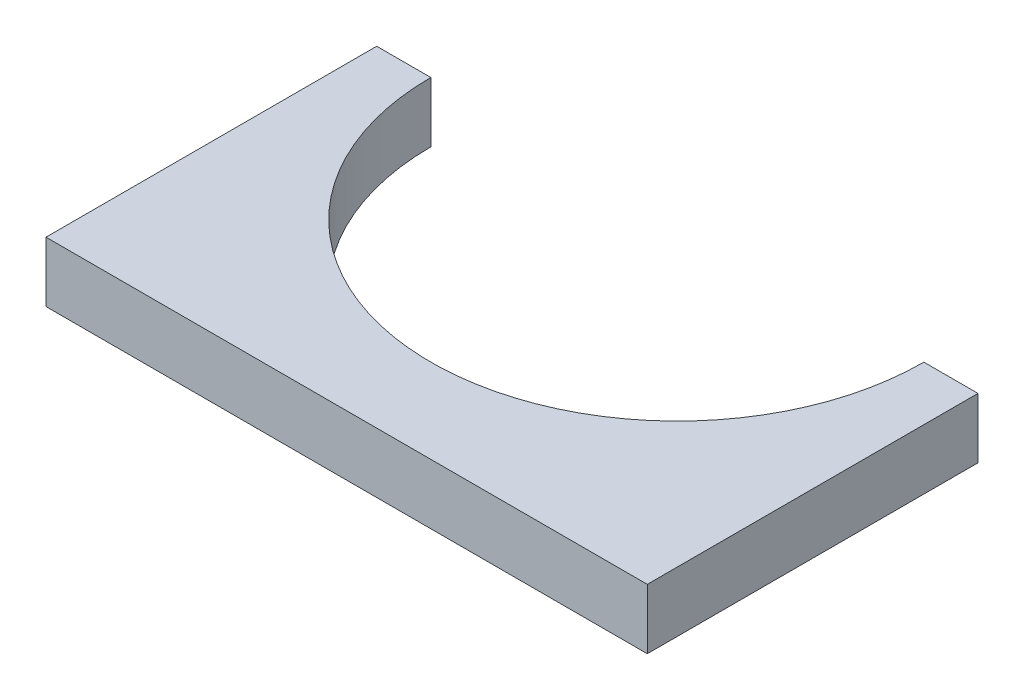
from build123d import *

# Parameters (mm, degrees)
EXTRUDE_1_DEPTH = 20


with BuildPart() as part:
    # Эскиз1 → Бобышка-Вытянуть1 (new body)
    with BuildSketch(Plane(origin=(0, 0, 0), x_dir=(1, 0, 0), z_dir=(0, 1, 0))):
        with BuildLine():
            Line((-100, 0), (100, 0))
            Line((100, 0), (100, 110))
            Line((100, 110), (82, 110))
            ThreePointArc((82, 110), (0, 28), (-82, 110))
            Line((-82, 110), (-100, 110))
            Line((-100, 110), (-100, 0))
        make_face()
    extrude(amount=EXTRUDE_1_DEPTH)


solid = part.part
